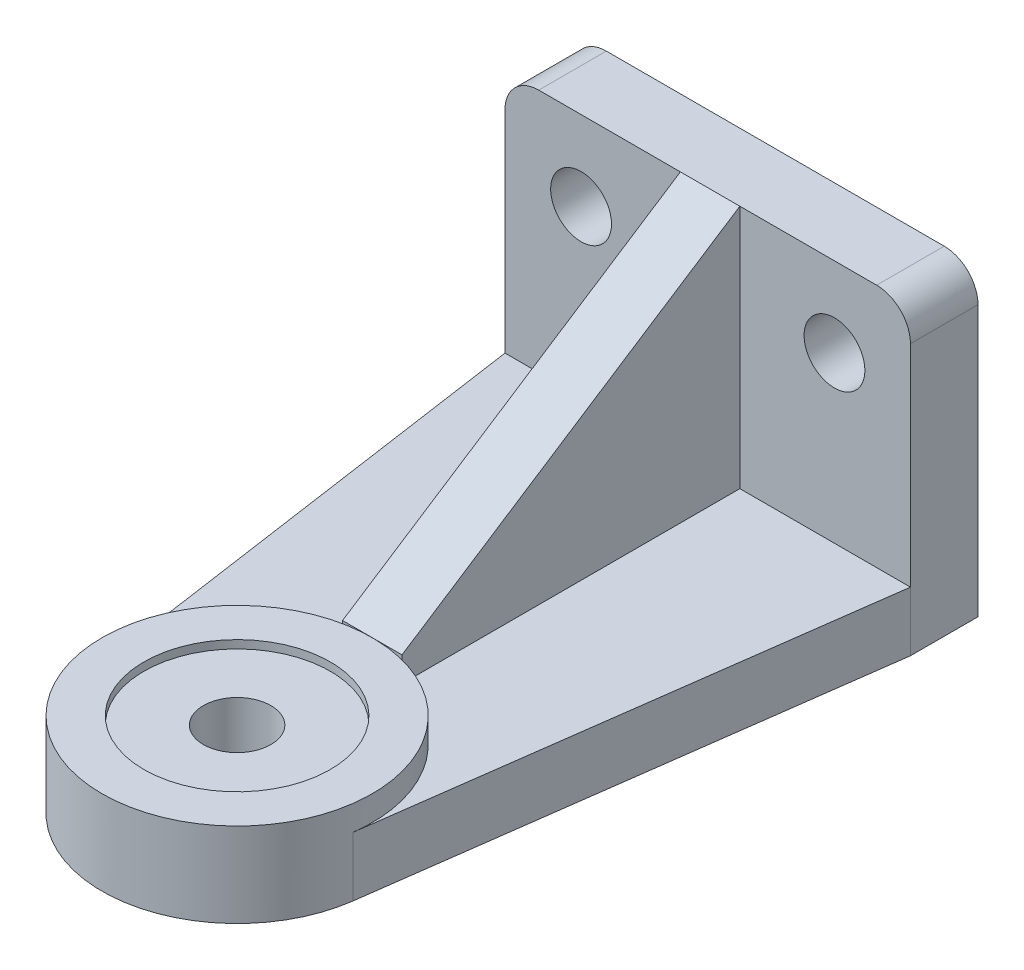
from build123d import *

# Parameters (mm, degrees)
BOSS_EXTRUDE1_DEPTH                  = 15.875
CUT_EXTRUDE1_START                   = -4.699
CUT_EXTRUDE1_DEPTH                   = 4.699
SKETCH4_W                            = 76.2
SKETCH4_H                            = 57.15
BOSS_EXTRUDE2_DEPTH                  = 12.7
BOSS_EXTRUDE4_DEPTH                  = 5.588
SKETCH9_W                            = 5.715
SKETCH9_H                            = 12.7
F_1_4_0_45_DIAMETER_HOLE1_AT_2_COUNT = 2
F_1_4_0_45_DIAMETER_HOLE1_AT_2_PITCH = 47.625
FILLET1_R                            = 6.35


with BuildPart() as part:
    # Sketch1 → Boss-Extrude1 (new body)
    with BuildSketch(Plane(origin=(0, 0, 0), x_dir=(1, 0, 0), z_dir=(0, 1, 0))):
        with BuildLine():
            Line((-25.137268282, -3.643863787), (-38.552299312, 88.9))
            Line((-38.552299312, 88.9), (37.647700688, 88.9))
            Line((37.647700688, 88.9), (25.171087732, -3.40240244))
            ThreePointArc((25.171087732, -3.40240244), (0.121909123, -25.399707443), (-25.137268282, -3.643863787))
        make_face()
    extrude(amount=BOSS_EXTRUDE1_DEPTH)

    # Sketch2 → Cut-Extrude1 (cut)
    with BuildSketch(Plane(origin=(0, 15.875, 0), x_dir=(1, 0, 0), z_dir=(0, 1, 0)).offset(CUT_EXTRUDE1_START)):
        with BuildLine():
            Line((-38.552299312, 88.9), (37.647700688, 88.9))
            Line((37.647700688, 88.9), (25.171087732, -3.40240244))
            ThreePointArc((25.171087732, -3.40240244), (-0.121909123, 25.399707443), (-25.137268282, -3.643863787))
            Line((-25.137268282, -3.643863787), (-38.552299312, 88.9))
        make_face()
    extrude(amount=CUT_EXTRUDE1_DEPTH, mode=Mode.SUBTRACT)

    # Sketch4 → Boss-Extrude2 (add)
    with BuildSketch(Plane(origin=(0, 0, -88.9), x_dir=(-1, 0, 0), z_dir=(0, 0, -1))):
        with Locations((0.452299312, 28.575)):
            Rectangle(SKETCH4_W, SKETCH4_H)
    extrude(amount=BOSS_EXTRUDE2_DEPTH)

    # Sketch7 → CBORE for 1_4 Binding Head Machine Screw (revolve, cut)
    with BuildSketch(Plane(origin=(0, 15.875, 0), x_dir=(0, 0, 1), z_dir=(1, 0, 0))):
        Polygon((0, 0), (0, 15.875), (6.35, 15.875), (6.35, 1.524), (17.526, 1.524), (17.526, 0), align=None)
    revolve(axis=Axis((0, 22.225, 0), (0, -1, 0)), mode=Mode.SUBTRACT)

    # Sketch9 → 1_4 _0.45_ Diameter Hole1 (revolve, cut)
    with BuildSketch(Plane(origin=(-24.252099312, 42.164, -88.9), x_dir=(0, -1, 0), z_dir=(1, 0, 0))):
        with Locations((2.8575, 6.35)):
            Rectangle(SKETCH9_W, SKETCH9_H)
    f_1_4_0_45_diameter_hole1 = revolve(axis=Axis((-24.252099312, 42.164, -82.55), (0, 0, -1)), mode=Mode.SUBTRACT)

    # 1_4 _0.45_ Diameter Hole1 at 2: 1_4 _0.45_ Diameter Hole1 ×2
    with Locations(*[(i * F_1_4_0_45_DIAMETER_HOLE1_AT_2_PITCH, 0, 0) for i in range(1, F_1_4_0_45_DIAMETER_HOLE1_AT_2_COUNT)]):
        add(f_1_4_0_45_diameter_hole1, mode=Mode.SUBTRACT)

    # Fillet1
    fillet1_edges = [part.edges().sort_by_distance(p)[0] for p in [
        (37.647700688, 57.15, -95.25),
        (-38.552299312, 57.15, -95.25),
    ]]
    fillet(fillet1_edges, radius=FILLET1_R)


with BuildPart() as body_2:
    # Sketch5 → Boss-Extrude4 (new, symmetric)
    with BuildSketch(Plane(origin=(0, 0, 0), x_dir=(0, 0, -1), z_dir=(1, 0, 0))):
        Polygon((88.9, 57.15), (25.4, 15.875), (25.4, 11.176), (88.9, 11.176), align=None)
    extrude(amount=BOSS_EXTRUDE4_DEPTH, both=True)


solid = Compound([part.part, body_2.part])
